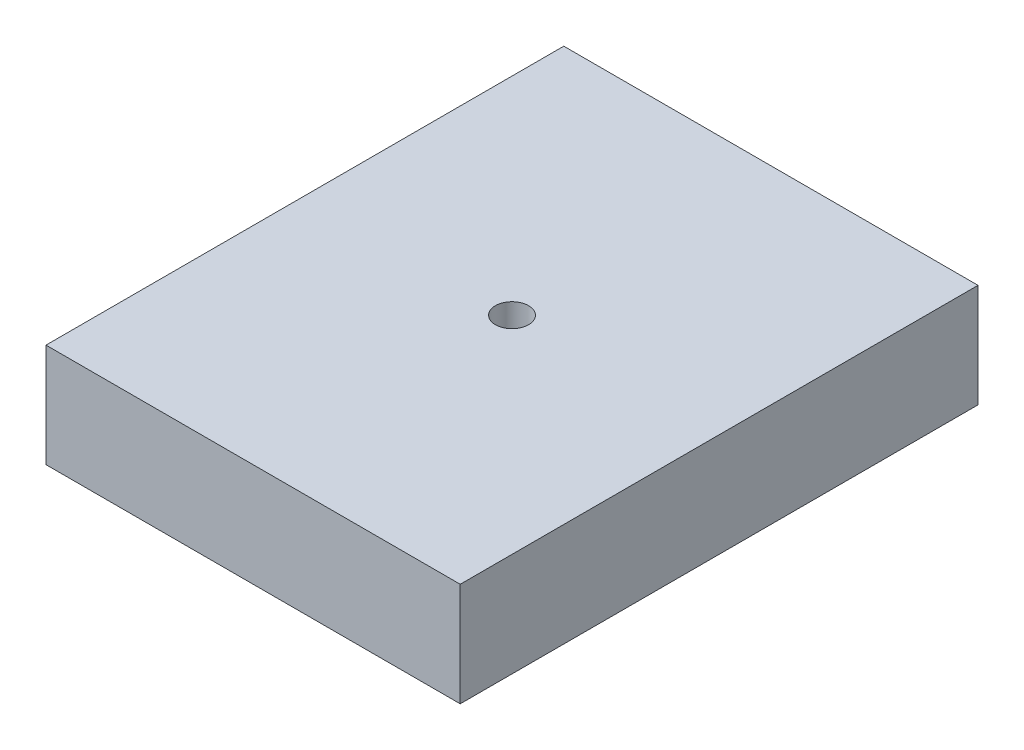
from build123d import *

# Parameters (mm, degrees)
ESBO_O1_W                    = 200
ESBO_O1_H                    = 250
RESSALTO_EXTRUS_O1_DEPTH     = 50
FURO_DE_DI_METRO_16_0_16_1_D = 16
PADR_O_LINEAR1_COUNT         = 3
PADR_O_LINEAR1_PITCH         = 30
PADR_O_LINEAR1_COUNT_DIR2    = 2
PADR_O_LINEAR1_PITCH_DIR2    = 120
ESBO_O7_W                    = 1.03
ESBO_O7_H                    = 10.3
RESSALTO_EXTRUS_O2_DEPTH     = 1


with BuildPart() as part:
    # Esboço1 → Ressalto-extrusão1 (new body)
    with BuildSketch(Plane(origin=(0, 0, 0), x_dir=(1, 0, 0), z_dir=(0, 1, 0))):
        with Locations((0, 125)):
            Rectangle(ESBO_O1_W, ESBO_O1_H)
    extrude(amount=RESSALTO_EXTRUS_O1_DEPTH)

    # Furo de diâmetro Ø16.0 (16)1 (through all)
    with Locations(Plane(origin=(0, 50, 0), x_dir=(1, 0, 0), z_dir=(0, 1, 0))):
        with Locations((0, 125)):
            Hole(FURO_DE_DI_METRO_16_0_16_1_D / 2)

    # Esboço5 → Corte-Revolução1 (revolve, cut)
    with BuildSketch(Plane.XZ):
        with BuildLine():
            Line((0, -27), (0, -223))
            ThreePointArc((0, -223), (2.121320344, -222.121320344), (3, -220))
            Line((3, -220), (3, -30))
            ThreePointArc((3, -30), (2.121320344, -27.878679656), (0, -27))
        make_face()
    revolve(axis=Axis((0, 0, -27), (0, 0, -1)), mode=Mode.SUBTRACT)

    # Esboço6 → Corte-Revolução2 (revolve, cut)
    with BuildSketch(Plane.XZ):
        with BuildLine():
            Line((-9, -34.85), (0, -34.85))
            Line((0, -34.85), (0, -31.85))
            Line((0, -31.85), (-6, -31.85))
            ThreePointArc((-6, -31.85), (-8.121320344, -32.728679656), (-9, -34.85))
        make_face()
    corte_revolu_o2 = revolve(axis=Axis((-9, 0, -34.85), (1, 0, 0)), mode=Mode.SUBTRACT)

    # Padrão linear1: Corte-Revolu_o2 3 × 2
    with Locations(*[Vector(0, 0, -1) * (i * PADR_O_LINEAR1_PITCH) + Vector(0, 0, -1) * (j * PADR_O_LINEAR1_PITCH_DIR2) for i in range(PADR_O_LINEAR1_COUNT) for j in range(PADR_O_LINEAR1_COUNT_DIR2) if (i, j) != (0, 0)]):
        add(corte_revolu_o2, mode=Mode.SUBTRACT)

    # Espelhar1: Corte-Revolução2 across plane
    add(corte_revolu_o2.mirror(Plane(origin=(0, 0, 0), x_dir=(0, 0, 1), z_dir=(1, 0, 0))), mode=Mode.SUBTRACT)

    # Espelhar1 copy 1 sketch → Espelhar1 copy 1 (revolve, cut)
    with BuildSketch(Plane(origin=(0, 0, -120), x_dir=(-1, 0, 0), z_dir=(0, -1, 0))):
        with BuildLine():
            Line((-9, 34.85), (0, 34.85))
            Line((0, 34.85), (0, 31.85))
            Line((0, 31.85), (-6, 31.85))
            ThreePointArc((-6, 31.85), (-8.121320344, 32.728679656), (-9, 34.85))
        make_face()
    revolve(axis=Axis((9, 0, -154.85), (1, 0, 0)), mode=Mode.SUBTRACT)

    # Espelhar1 copy 2 sketch → Espelhar1 copy 2 (revolve, cut)
    with BuildSketch(Plane(origin=(0, 0, -30), x_dir=(-1, 0, 0), z_dir=(0, -1, 0))):
        with BuildLine():
            Line((-9, 34.85), (0, 34.85))
            Line((0, 34.85), (0, 31.85))
            Line((0, 31.85), (-6, 31.85))
            ThreePointArc((-6, 31.85), (-8.121320344, 32.728679656), (-9, 34.85))
        make_face()
    revolve(axis=Axis((9, 0, -64.85), (1, 0, 0)), mode=Mode.SUBTRACT)

    # Espelhar1 copy 3 sketch → Espelhar1 copy 3 (revolve, cut)
    with BuildSketch(Plane(origin=(0, 0, -150), x_dir=(-1, 0, 0), z_dir=(0, -1, 0))):
        with BuildLine():
            Line((-9, 34.85), (0, 34.85))
            Line((0, 34.85), (0, 31.85))
            Line((0, 31.85), (-6, 31.85))
            ThreePointArc((-6, 31.85), (-8.121320344, 32.728679656), (-9, 34.85))
        make_face()
    revolve(axis=Axis((9, 0, -184.85), (1, 0, 0)), mode=Mode.SUBTRACT)

    # Espelhar1 copy 4 sketch → Espelhar1 copy 4 (revolve, cut)
    with BuildSketch(Plane(origin=(0, 0, -60), x_dir=(-1, 0, 0), z_dir=(0, -1, 0))):
        with BuildLine():
            Line((-9, 34.85), (0, 34.85))
            Line((0, 34.85), (0, 31.85))
            Line((0, 31.85), (-6, 31.85))
            ThreePointArc((-6, 31.85), (-8.121320344, 32.728679656), (-9, 34.85))
        make_face()
    revolve(axis=Axis((9, 0, -94.85), (1, 0, 0)), mode=Mode.SUBTRACT)

    # Espelhar1 copy 5 sketch → Espelhar1 copy 5 (revolve, cut)
    with BuildSketch(Plane(origin=(0, 0, -180), x_dir=(-1, 0, 0), z_dir=(0, -1, 0))):
        with BuildLine():
            Line((-9, 34.85), (0, 34.85))
            Line((0, 34.85), (0, 31.85))
            Line((0, 31.85), (-6, 31.85))
            ThreePointArc((-6, 31.85), (-8.121320344, 32.728679656), (-9, 34.85))
        make_face()
    revolve(axis=Axis((9, 0, -214.85), (1, 0, 0)), mode=Mode.SUBTRACT)

    # Esboço7 → Ressalto-extrusão2 (add)
    with BuildSketch(Plane.XZ):
        with Locations((-41.415, -35.15)):
            Rectangle(ESBO_O7_W, ESBO_O7_H)
        with Locations((-41.415, -65.15)):
            Rectangle(ESBO_O7_W, ESBO_O7_H)
        with Locations((-41.415, -95.15)):
            Rectangle(ESBO_O7_W, ESBO_O7_H)
        with Locations((-41.415, -154.85)):
            Rectangle(ESBO_O7_W, ESBO_O7_H)
        with Locations((-41.415, -184.85)):
            Rectangle(ESBO_O7_W, ESBO_O7_H)
        with Locations((-41.415, -214.85)):
            Rectangle(ESBO_O7_W, ESBO_O7_H)
        with Locations((41.415, -214.85)):
            Rectangle(ESBO_O7_W, ESBO_O7_H)
        with Locations((41.415, -184.85)):
            Rectangle(ESBO_O7_W, ESBO_O7_H)
        with Locations((41.415, -154.85)):
            Rectangle(ESBO_O7_W, ESBO_O7_H)
        with Locations((41.415, -95.15)):
            Rectangle(ESBO_O7_W, ESBO_O7_H)
        with Locations((41.415, -65.15)):
            Rectangle(ESBO_O7_W, ESBO_O7_H)
        with Locations((41.415, -35.15)):
            Rectangle(ESBO_O7_W, ESBO_O7_H)
    extrude(amount=RESSALTO_EXTRUS_O2_DEPTH)


solid = part.part
